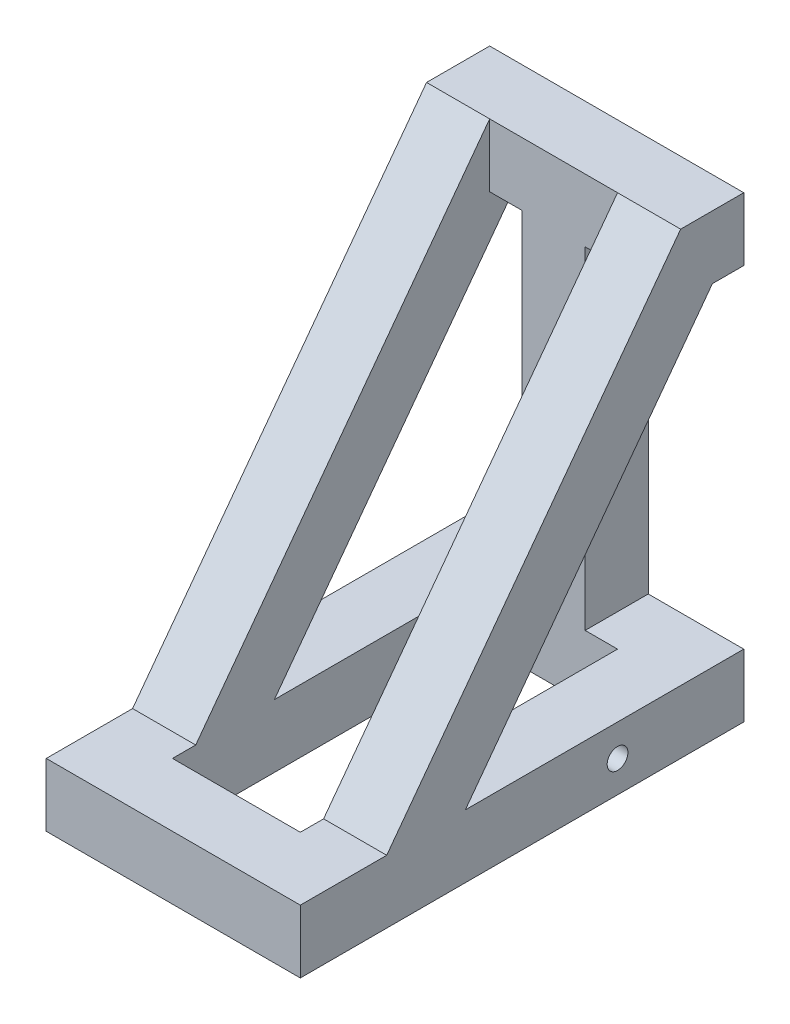
from build123d import *

# Parameters (mm, degrees)
SKETCH1_W                = 153
SKETCH1_H                = 267
SKETCH1_W_2              = 77
SKETCH1_H_2              = 191
BOSS_EXTRUDE1_DEPTH      = 38
SKETCH2_W                = 38
SKETCH2_H                = 38
BOSS_EXTRUDE2_DEPTH      = 200
SKETCH3_W                = 38
SKETCH3_H                = 38
BOSS_EXTRUDE3_DEPTH      = 76.5
BOSS_EXTRUDE3_DEPTH_BACK = 76.5
BOSS_EXTRUDE4_DEPTH      = 38
SKETCH7_R                = 6.25
CUT_EXTRUDE1_DEPTH       = 154


with BuildPart() as part:
    # Sketch1 → Boss-Extrude1 (new body)
    with BuildSketch(Plane(origin=(0, 0, 0), x_dir=(1, 0, 0), z_dir=(0, 1, 0))):
        Rectangle(SKETCH1_W, SKETCH1_H)
        Rectangle(SKETCH1_W_2, SKETCH1_H_2, mode=Mode.SUBTRACT)
    extrude(amount=BOSS_EXTRUDE1_DEPTH)

    # Sketch2 → Boss-Extrude2 (add)
    with BuildSketch(Plane(origin=(0, 38, 0), x_dir=(1, 0, 0), z_dir=(0, 1, 0))):
        with Locations((0, 114.5)):
            Rectangle(SKETCH2_W, SKETCH2_H)
    extrude(amount=BOSS_EXTRUDE2_DEPTH)

    # Sketch3 → Boss-Extrude3 (add, two sides)
    with BuildSketch(Plane(origin=(0, 0, 0), x_dir=(0, 0, -1), z_dir=(1, 0, 0))) as boss_extrude3_sk:
        with Locations((114.5, 257)):
            Rectangle(SKETCH3_W, SKETCH3_H)
    extrude(amount=BOSS_EXTRUDE3_DEPTH)
    extrude(boss_extrude3_sk.sketch, amount=-BOSS_EXTRUDE3_DEPTH_BACK)

    # Sketch6 → Boss-Extrude4 (add)
    with BuildSketch(Plane(origin=(76.5, 0, 0), x_dir=(0, 0, -1), z_dir=(1, 0, 0))):
        Polygon((95.5, 276), (-81.5, 38), (-34.143309895, 38), (114.596185904, 238), (95.5, 238), align=None)
    boss_extrude4 = extrude(amount=-BOSS_EXTRUDE4_DEPTH)

    # Mirror1: Boss-Extrude4 across plane
    add(boss_extrude4.mirror(Plane(origin=(0, 0, 0), x_dir=(0, 0, 1), z_dir=(1, 0, 0))))

    # Sketch7 → Cut-Extrude1 (cut, through all)
    with BuildSketch(Plane(origin=(76.5, 0, 0), x_dir=(0, 0, -1), z_dir=(1, 0, 0))):
        with Locations((57.5, 19)):
            Circle(SKETCH7_R)
    extrude(amount=-CUT_EXTRUDE1_DEPTH, mode=Mode.SUBTRACT)


solid = part.part
